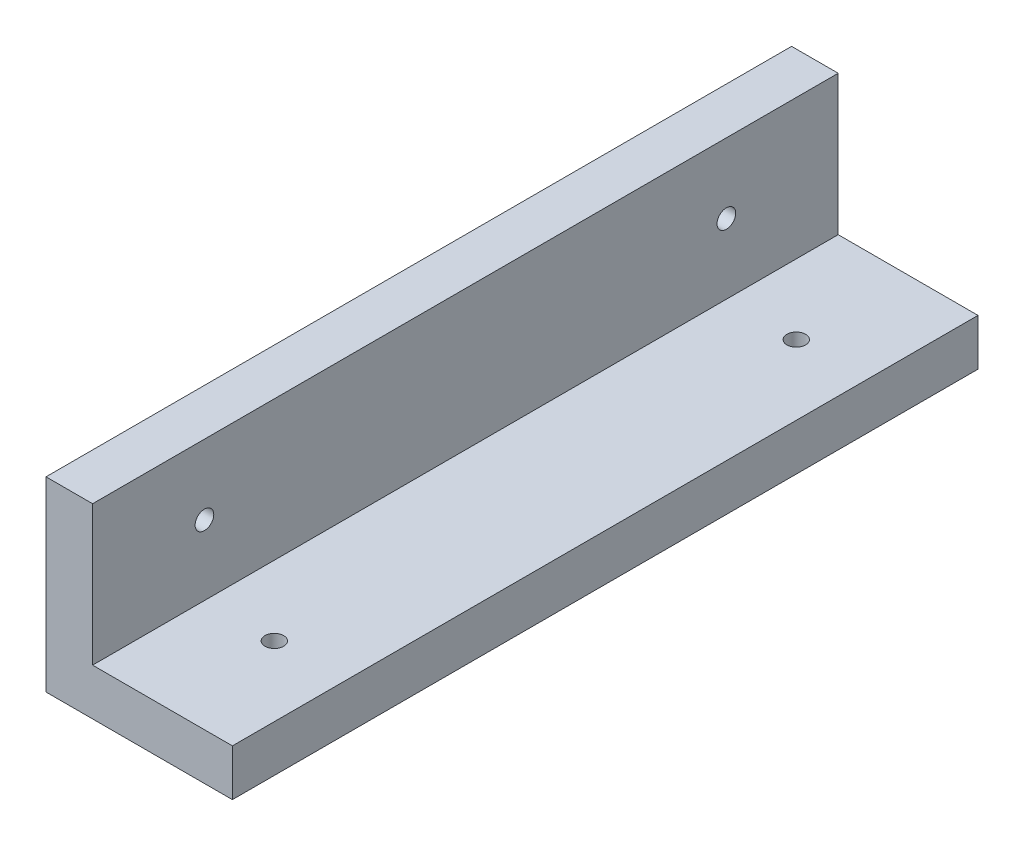
from build123d import *

# Parameters (mm, degrees)
EXTRUDE_1_DEPTH          = 80
SKETCH_2_R               = 1
CUT_EXTRUDE_2_DEPTH      = 10
CUT_EXTRUDE_2_DEPTH_BACK = 10
SKETCH_3_R               = 1
CUT_EXTRUDE_3_DEPTH      = 10
CUT_EXTRUDE_3_DEPTH_BACK = 10


with BuildPart() as part:
    # 草圖1 → 填料-伸長1 (new body)
    with BuildSketch(Plane.XY):
        Polygon((0, 0), (0, 20), (5, 20), (5, 5), (20, 5), (20, 0), align=None)
    extrude(amount=EXTRUDE_1_DEPTH)

    # 草圖2 → 除料-伸長2 (cut, two sides)
    with BuildSketch(Plane(origin=(0, 0, 0), x_dir=(1, 0, 0), z_dir=(0, 1, 0))) as cut_extrude_2_sk:
        with Locations((12.5, -12)):
            Circle(SKETCH_2_R)
        with Locations((12.5, -68)):
            Circle(SKETCH_2_R)
    extrude(amount=CUT_EXTRUDE_2_DEPTH, mode=Mode.SUBTRACT)
    extrude(cut_extrude_2_sk.sketch, amount=-CUT_EXTRUDE_2_DEPTH_BACK, mode=Mode.SUBTRACT)

    # 草圖3 → 除料-伸長3 (cut, two sides)
    with BuildSketch(Plane(origin=(0, 0, 0), x_dir=(0, 0, -1), z_dir=(1, 0, 0))) as cut_extrude_3_sk:
        with Locations((-12, 12.5)):
            Circle(SKETCH_3_R)
        with Locations((-68, 12.5)):
            Circle(SKETCH_3_R)
    extrude(amount=CUT_EXTRUDE_3_DEPTH, mode=Mode.SUBTRACT)
    extrude(cut_extrude_3_sk.sketch, amount=-CUT_EXTRUDE_3_DEPTH_BACK, mode=Mode.SUBTRACT)


solid = part.part
